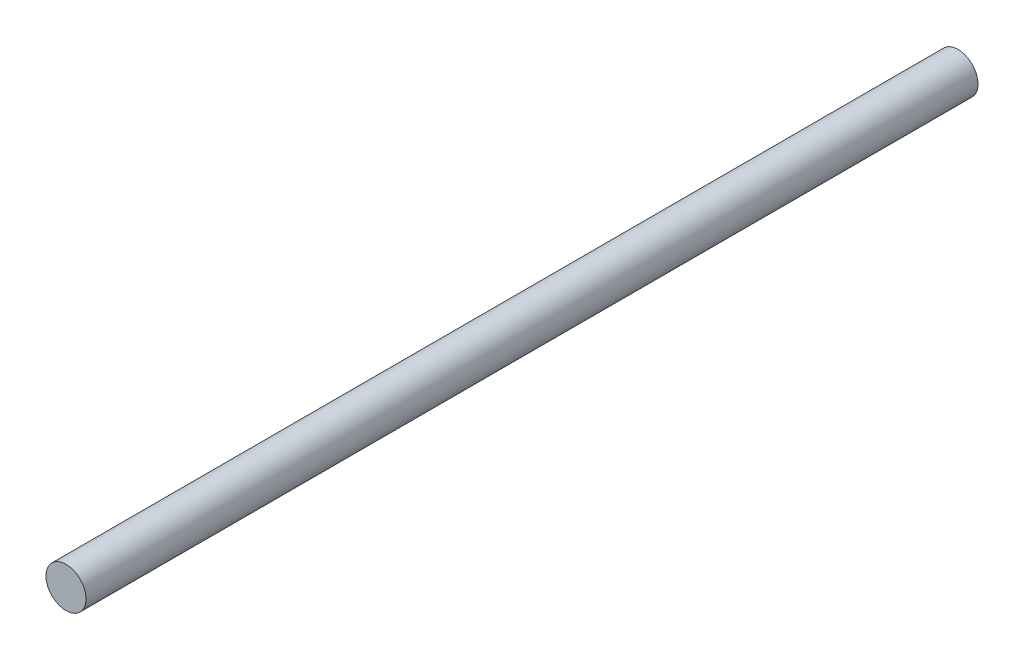
from build123d import *

# Parameters (mm, degrees)
SKETCH1_R           = 10
BOSS_EXTRUDE1_DEPTH = 222.5


with BuildPart() as part:
    # Sketch1 → Boss-Extrude1 (new body, symmetric)
    with BuildSketch(Plane.XY):
        Circle(SKETCH1_R)
    extrude(amount=BOSS_EXTRUDE1_DEPTH, both=True)


solid = part.part
